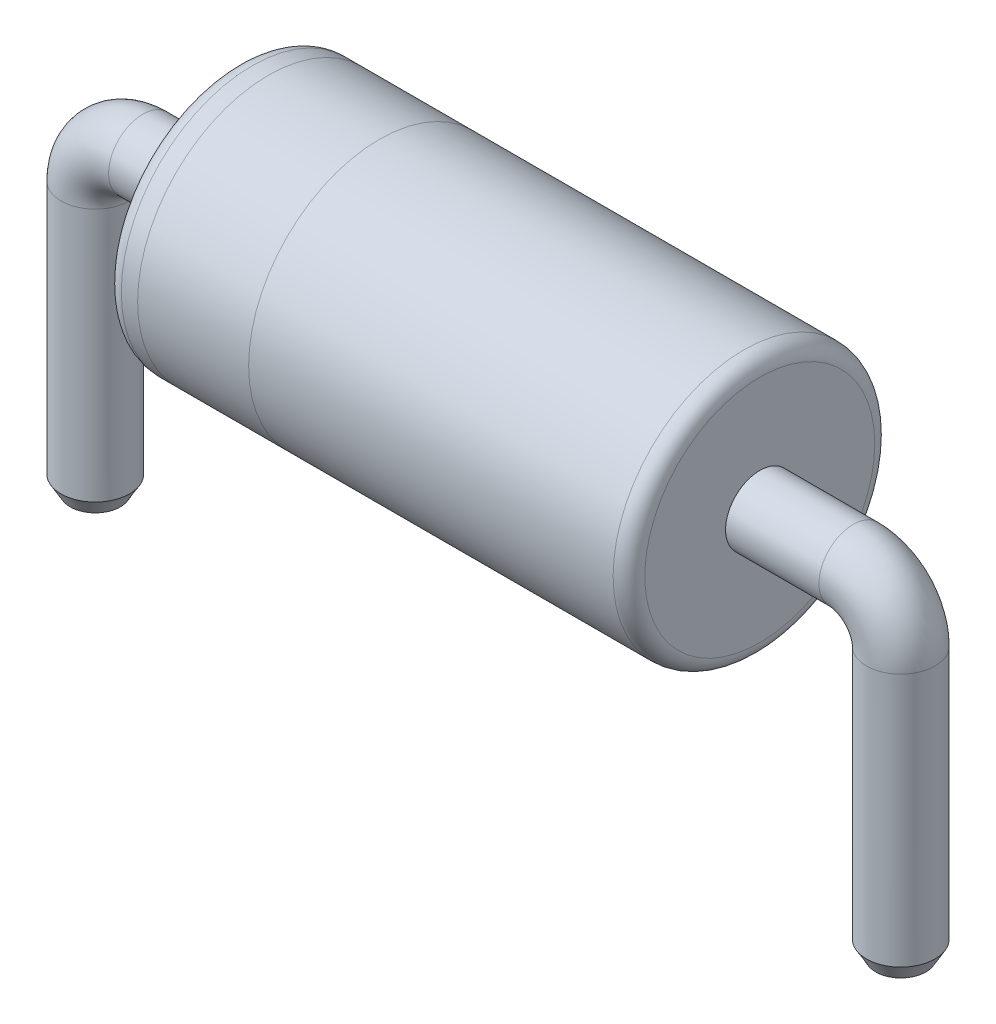
from build123d import *

# Parameters (mm, degrees)
SKETCH1_R             = 0.2159
SKETCH3_R             = 0.825
EXTRUDE1_DEPTH        = 3.302
FILLET1_R             = 0.1
CHAMFER1_SIZE         = 0.1
CHAMFER1_SIZE2        = 0.057735027
CHAMFER1_PART_2_SIZE  = 0.1
CHAMFER1_PART_2_SIZE2 = 0.057735027


with BuildPart() as part:
    # Sweep1: sweep along a path in Sketch2
    with BuildLine(Plane.XY) as sweep1_path:
        Line((0, 0), (0, 1.7))
        ThreePointArc((0, 1.7), (-0.087867966, 1.912132034), (-0.3, 2))
        Line((-0.3, 2), (-4.78, 2))
        ThreePointArc((-4.78, 2), (-4.992132034, 1.912132034), (-5.08, 1.7))
        Line((-5.08, 1.7), (-5.08, 0))
    # Sketch1 → Sweep1 (sweep)
    with BuildSketch(Plane(origin=(0, 0, 0), x_dir=(1, 0, 0), z_dir=(0, 1, 0))):
        Circle(SKETCH1_R)
    sweep(path=sweep1_path.line)

    # Sketch3 → Extrude1 (add)
    with BuildSketch(Plane(origin=(-0.889, 0, 0), x_dir=(0, 0, -1), z_dir=(1, 0, 0))):
        with Locations((0, 2)):
            Circle(SKETCH3_R)
    extrude(amount=-EXTRUDE1_DEPTH)

    # Fillet1
    fillet1_edges = [part.edges().sort_by_distance(p)[0] for p in [
        (-4.191, 2, 0.825),
        (-0.889, 2, 0.825),
    ]]
    fillet(fillet1_edges, radius=FILLET1_R)

    # Chamfer1
    chamfer1_edges = [part.edges().sort_by_distance(p)[0] for p in [
        (-0.2159, 0, 0),
    ]]
    chamfer1_side = [part.faces().sort_by_distance(p)[0] for p in [
        (-0.2159, 0.85, 0),
    ]]
    chamfer(chamfer1_edges, length=CHAMFER1_SIZE, length2=CHAMFER1_SIZE2, reference=chamfer1_side[0])

    # Chamfer1 part 2
    chamfer1_part_2_edges = [part.edges().sort_by_distance(p)[0] for p in [
        (-4.8641, 0, 0),
    ]]
    chamfer1_part_2_side = [part.faces().sort_by_distance(p)[0] for p in [
        (-4.8641, 0.85, 0),
    ]]
    chamfer(chamfer1_part_2_edges, length=CHAMFER1_PART_2_SIZE, length2=CHAMFER1_PART_2_SIZE2, reference=chamfer1_part_2_side[0])


solid = part.part
